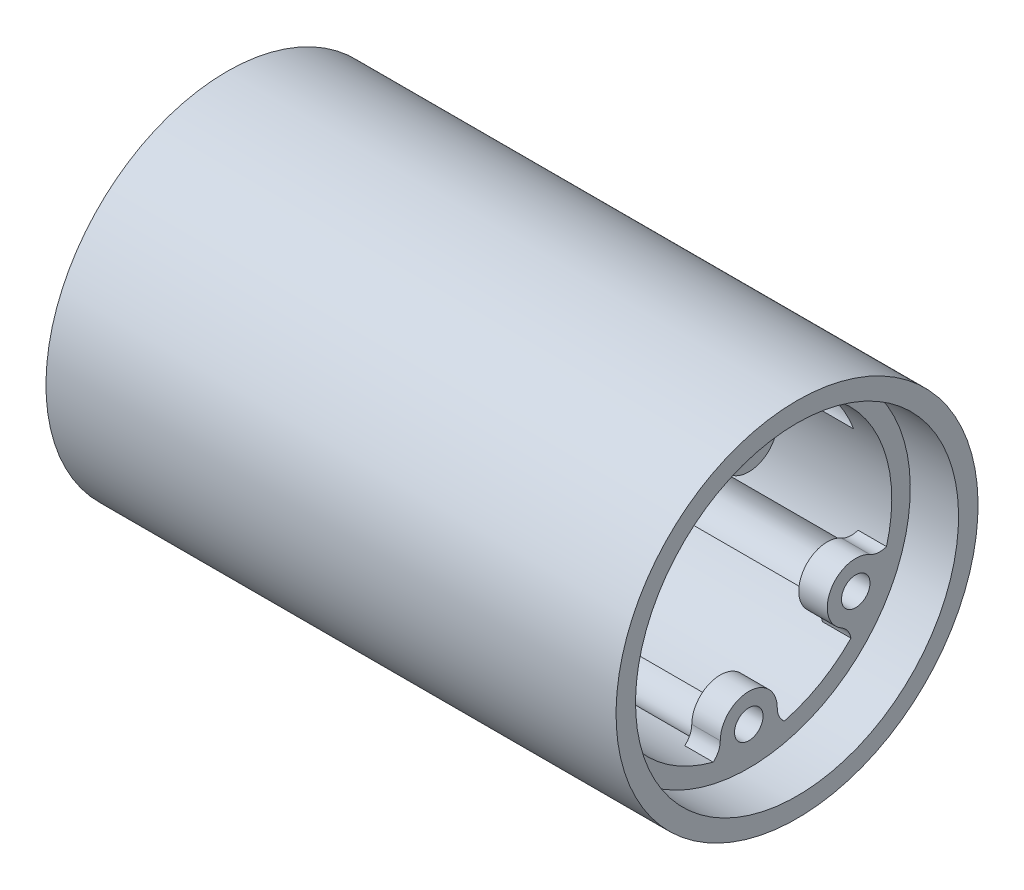
from build123d import *

# Parameters (mm, degrees)
SKETCH1_W           = 60
SKETCH1_H           = 2.05
SKETCH1_W_2         = 47.3
SKETCH1_H_2         = 1.95
SKETCH1_W_3         = 1.27
SKETCH1_W_4         = 6.35
SKETCH2_R           = 1.5
BOSS_EXTRUDE1_DEPTH = 3
SKETCH5_R           = 1.5
CUT_EXTRUDE1_DEPTH  = 10
SKETCH6_R           = 3
SKETCH6_R_2         = 15.05
CUT_EXTRUDE2_DEPTH  = 51.92


with BuildPart() as part:
    # Sketch1 → Revolve1 (revolve)
    with BuildSketch(Plane.XY):
        with Locations((0, 18.025)):
            Rectangle(SKETCH1_W, SKETCH1_H)
        with Locations((0, 16.025)):
            Rectangle(SKETCH1_W_2, SKETCH1_H_2)
        with Locations((24.285, 16.025)):
            Rectangle(SKETCH1_W_3, SKETCH1_H_2)
        with Locations((-26.825, 16.025)):
            Rectangle(SKETCH1_W_4, SKETCH1_H_2)
    revolve(axis=Axis((0, 0, 0), (-1, 0, 0)))

    # Sketch2 → Boss-Extrude1 (add)
    with BuildSketch(Plane(origin=(24.92, 0, 0), x_dir=(0, 0, -1), z_dir=(1, 0, 0))):
        with BuildLine():
            ThreePointArc((-3.73983832, 14.577932273), (-3.194140619, 13.871382665), (-3, 13))
            ThreePointArc((-3, 13), (0, 10), (3, 13))
            ThreePointArc((3, 13), (3.194140619, 13.871382665), (3.73983832, 14.577932273))
            ThreePointArc((3.73983832, 14.577932273), (0, 15.05), (-3.73983832, 14.577932273))
        make_face()
        with Locations((0, 13)):
            Circle(SKETCH2_R, mode=Mode.SUBTRACT)
        with BuildLine():
            ThreePointArc((-9.758330249, 9.098076211), (-10.415899464, 9.701898251), (-10.754940523, 10.527761127))
            ThreePointArc((-10.754940523, 10.527761127), (-13.033682327, 7.525), (-14.494778842, 4.050171146))
            ThreePointArc((-14.494778842, 4.050171146), (-13.610040083, 4.169484414), (-12.758330249, 3.901923789))
            ThreePointArc((-12.758330249, 3.901923789), (-8.660254038, 5), (-9.758330249, 9.098076211))
        make_face()
        with Locations((-11.258330249, 6.5)):
            Circle(SKETCH2_R, mode=Mode.SUBTRACT)
        with BuildLine():
            ThreePointArc((10.754940523, -10.527761127), (13.033682327, -7.525), (14.494778842, -4.050171146))
            ThreePointArc((14.494778842, -4.050171146), (13.610040083, -4.169484414), (12.758330249, -3.901923789))
            ThreePointArc((12.758330249, -3.901923789), (8.660254038, -5), (9.758330249, -9.098076211))
            ThreePointArc((9.758330249, -9.098076211), (10.415899464, -9.701898251), (10.754940523, -10.527761127))
        make_face()
        with Locations((11.258330249, -6.5)):
            Circle(SKETCH2_R, mode=Mode.SUBTRACT)
        with BuildLine():
            ThreePointArc((-3, -13), (-3.194140619, -13.871382665), (-3.73983832, -14.577932273))
            ThreePointArc((-3.73983832, -14.577932273), (0, -15.05), (3.73983832, -14.577932273))
            ThreePointArc((3.73983832, -14.577932273), (3.194140619, -13.871382665), (3, -13))
            ThreePointArc((3, -13), (0, -10), (-3, -13))
        make_face()
        with Locations((0, -13)):
            Circle(SKETCH2_R, mode=Mode.SUBTRACT)
    extrude(amount=-BOSS_EXTRUDE1_DEPTH)

    # Sketch5 → Cut-Extrude1 (cut)
    with BuildSketch(Plane.ZY.offset(30)):
        with Locations((-8.525, -14.765733135)):
            Circle(SKETCH5_R)
        with Locations((8.525, -14.765733135)):
            Circle(SKETCH5_R)
        with Locations((17.05, 0)):
            Circle(SKETCH5_R)
        with Locations((-17.05, 0)):
            Circle(SKETCH5_R)
        with Locations((8.525, 14.765733135)):
            Circle(SKETCH5_R)
        with Locations((-8.525, 14.765733135)):
            Circle(SKETCH5_R)
    extrude(amount=-CUT_EXTRUDE1_DEPTH, mode=Mode.SUBTRACT)

    # Sketch6 → Cut-Extrude2 (cut)
    with BuildSketch(Plane.ZY.offset(30)):
        with Locations((-11.258330249, 6.5)):
            Circle(SKETCH6_R)
        Circle(SKETCH6_R_2)
        with Locations((-11.258330249, 6.5)):
            Circle(SKETCH6_R)
        Circle(SKETCH6_R_2)
        with Locations((0, 13)):
            Circle(SKETCH6_R)
        Circle(SKETCH6_R_2)
        with Locations((11.258330249, 6.5)):
            Circle(SKETCH6_R)
        Circle(SKETCH6_R_2)
        with Locations((11.258330249, 6.5)):
            Circle(SKETCH6_R)
        Circle(SKETCH6_R_2)
        with Locations((11.258330249, -6.5)):
            Circle(SKETCH6_R)
        Circle(SKETCH6_R_2)
        with Locations((11.258330249, -6.5)):
            Circle(SKETCH6_R)
        Circle(SKETCH6_R_2)
        with Locations((0, -13)):
            Circle(SKETCH6_R)
        Circle(SKETCH6_R_2)
        with Locations((0, -13)):
            Circle(SKETCH6_R)
        Circle(SKETCH6_R_2)
        with Locations((-11.258330249, -6.5)):
            Circle(SKETCH6_R)
        Circle(SKETCH6_R_2)
        with Locations((-11.258330249, -6.5)):
            Circle(SKETCH6_R)
        Circle(SKETCH6_R_2)
    extrude(amount=-CUT_EXTRUDE2_DEPTH, mode=Mode.SUBTRACT)


solid = part.part
